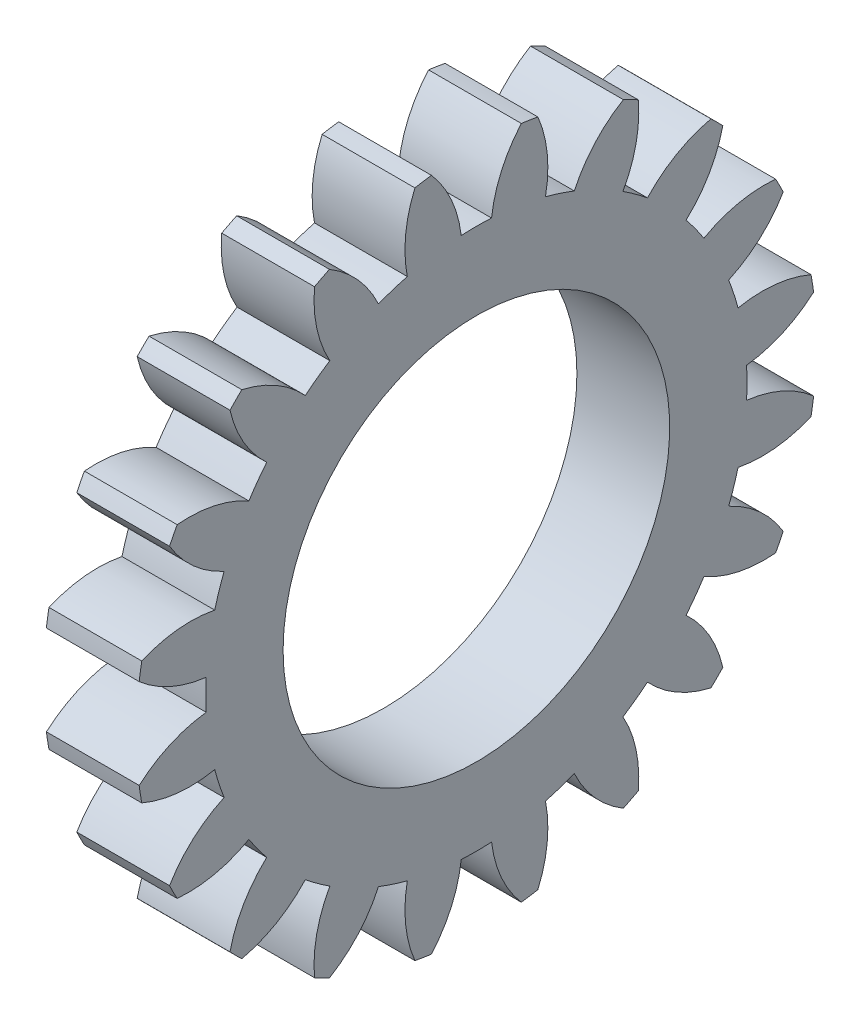
from build123d import *

# Parameters (mm, degrees)
BASPROSKE_W     = 12
BASPROSKE_H     = 44
TOOTHCUT_DEPTH  = 64.371918071
TEETHCUTS_COUNT = 20
TEETHCUTS_ANGLE = 342
BORSKE_R        = 25
BORE_DEPTH      = 50.0000508


with BuildPart() as part:
    # BasProSke → Base-Revolve (revolve)
    with BuildSketch(Plane(origin=(0, 0, 0), x_dir=(1, 0, 0), z_dir=(0, 1, 0)), mode=Mode.PRIVATE) as base_revolve_sk:
        with Locations((6, 22)):
            Rectangle(BASPROSKE_W, BASPROSKE_H)
    revolve(base_revolve_sk.sketch.rotate(Axis((-10, 0, 0), (1, 0, 0)), 180), axis=Axis((-10, 0, 0), (1, 0, 0)))

    # TooCutSke → ToothCut (cut, through all)
    with BuildSketch(Plane(origin=(0, 0, 0), x_dir=(0, 0, -1), z_dir=(1, 0, 0))):
        with BuildLine():
            ThreePointArc((1.961730392, 34.943978235), (0, 34.999), (-1.961730392, 34.943978235))
            ThreePointArc((-1.961730392, 34.943978235), (-3.235659864, 39.585086827), (-5.832115241, 43.637395396))
            ThreePointArc((-5.832115241, 43.637395396), (0, 44.0254), (5.832115241, 43.637395396))
            ThreePointArc((5.832115241, 43.637395396), (3.235659864, 39.585086827), (1.961730392, 34.943978235))
        make_face()
    toothcut = extrude(amount=TOOTHCUT_DEPTH, mode=Mode.SUBTRACT)

    # TeethCuts: ToothCut ×20 about axis
    teethcuts_axis = Axis((-10, 0, 0), (1, 0, 0))
    for i in range(1, TEETHCUTS_COUNT):
        add(toothcut.rotate(teethcuts_axis, i * TEETHCUTS_ANGLE / (TEETHCUTS_COUNT - 1)), mode=Mode.SUBTRACT)

    # BorSke → Bore (cut, symmetric)
    with BuildSketch(Plane(origin=(0, 0, 0), x_dir=(0, 0, -1), z_dir=(1, 0, 0))):
        with Locations(Location((0, 0, 0), (0, 0, 180))):
            Circle(BORSKE_R)
    extrude(amount=BORE_DEPTH, both=True, mode=Mode.SUBTRACT)


solid = part.part
